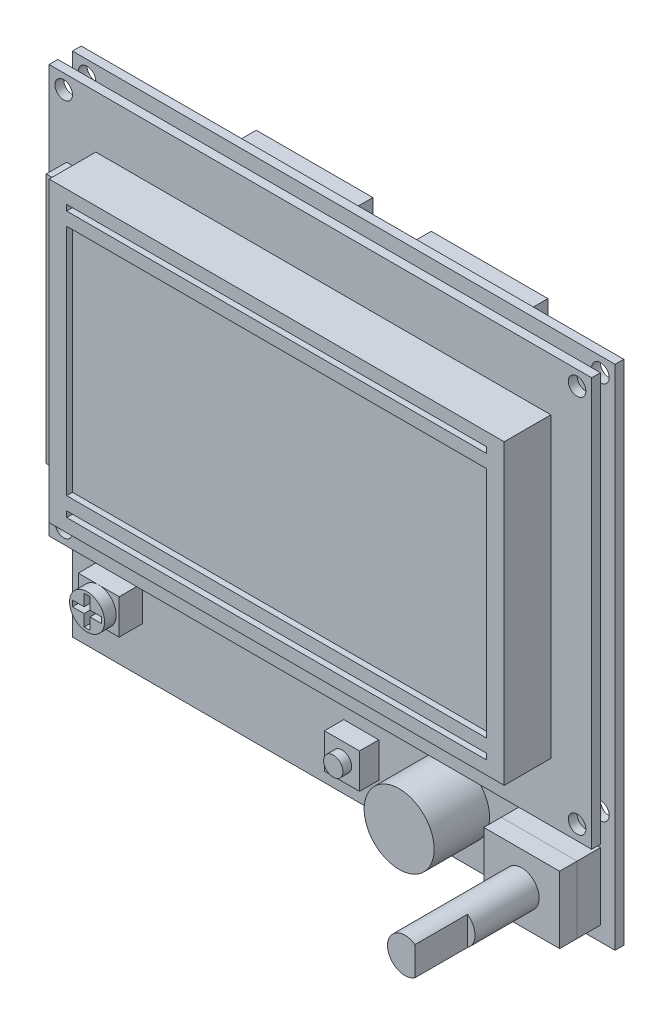
from build123d import *

# Parameters (mm, degrees)
ESQUISSE1_W             = 78
ESQUISSE1_H             = 51
BOSS_EXTRU_1_DEPTH      = 8
ESQUISSE2_W             = 72
ESQUISSE2_H             = 40
ESQUISSE2_H_2           = 1
ENL_V_MAT_EXTRU_1_DEPTH = 1
ESQUISSE3_W             = 5
ESQUISSE3_H             = 43
BOSS_EXTRU_2_DEPTH      = 3.5
ESQUISSE4_W             = 93
ESQUISSE4_H             = 70
ESQUISSE4_R             = 1.5
BOSS_EXTRU_3_DEPTH      = 1.5
ESQUISSE5_W             = 93
ESQUISSE5_H             = 87
ESQUISSE5_R             = 1.5
BOSS_EXTRU_4_DEPTH      = 1.5
BOSS_EXTRU_5_DEPTH      = 25
ESQUISSE7_W             = 20
ESQUISSE7_H             = 9
ESQUISSE7_W_2           = 18
ESQUISSE7_H_2           = 7
BOSS_EXTRU_6_DEPTH      = 9
BOSS_EXTRU_6_2_DEPTH    = 9
ESQUISSE8_W             = 13
ESQUISSE8_H             = 11.5
BOSS_EXTRU_7_DEPTH      = 4
ESQUISSE8_W_2           = 7
ESQUISSE8_H_2           = 6
BOSS_EXTRU_7_2_DEPTH    = 4
ESQUISSE9_W             = 13
ESQUISSE9_H             = 11.5
BOSS_EXTRU_8_DEPTH      = 3
ESQUISSE10_R            = 3
BOSS_EXTRU_9_DEPTH      = 20
ESQUISSE11_W            = 20.196518619
ESQUISSE11_H            = 4.923957274
ENL_V_MAT_EXTRU_2_DEPTH = 9
ESQUISSE12_R            = 6
BOSS_EXTRU_10_DEPTH     = 9.5
ESQUISSE13_R            = 3
BOSS_EXTRU_11_DEPTH     = 2
ESQUISSE14_W            = 6
ESQUISSE14_H            = 6
BOSS_EXTRU_12_DEPTH     = 3.3
ESQUISSE15_R            = 1.65
BOSS_EXTRU_13_DEPTH     = 1.5


with BuildPart() as part:
    # Esquisse1 → Boss.-Extru.1 (new body)
    with BuildSketch(Plane.XY):
        with Locations((0, 25.5)):
            Rectangle(ESQUISSE1_W, ESQUISSE1_H)
    extrude(amount=BOSS_EXTRU_1_DEPTH)

    # Esquisse2 → Enlèv. mat.-Extru.1 (cut)
    with BuildSketch(Plane.XY.offset(8)):
        with Locations((0, 25.5)):
            Rectangle(ESQUISSE2_W, ESQUISSE2_H)
        with Locations((0, 2.75)):
            Rectangle(ESQUISSE2_W, ESQUISSE2_H_2)
        with Locations((0, 48.25)):
            Rectangle(ESQUISSE2_W, ESQUISSE2_H_2)
    extrude(amount=-ENL_V_MAT_EXTRU_1_DEPTH, mode=Mode.SUBTRACT)


with BuildPart() as body_2:
    # Esquisse3 → Boss.-Extru.2 (new body)
    with BuildSketch(Plane(origin=(0, 0, 0), x_dir=(-1, 0, 0), z_dir=(0, 0, -1))):
        with Locations((41.5, 25.5)):
            Rectangle(ESQUISSE3_W, ESQUISSE3_H)
    extrude(amount=-BOSS_EXTRU_2_DEPTH)


with BuildPart() as body_3:
    # Esquisse4 → Boss.-Extru.3 (new body)
    with BuildSketch(Plane(origin=(0, 0, 0), x_dir=(-1, 0, 0), z_dir=(0, 0, -1))):
        with Locations((0.5, 25)):
            Rectangle(ESQUISSE4_W, ESQUISSE4_H)
        with Locations((-43.5, 57.5)):
            Circle(ESQUISSE4_R, mode=Mode.SUBTRACT)
        with Locations((-43.5, -7.5)):
            Circle(ESQUISSE4_R, mode=Mode.SUBTRACT)
        with Locations((44.5, 57.5)):
            Circle(ESQUISSE4_R, mode=Mode.SUBTRACT)
        with Locations((44.5, -7.5)):
            Circle(ESQUISSE4_R, mode=Mode.SUBTRACT)
    extrude(amount=BOSS_EXTRU_3_DEPTH)


with BuildPart() as body_4:
    # Esquisse5 → Boss.-Extru.4 (new body)
    with BuildSketch(Plane(origin=(0, 0, -4), x_dir=(-1, 0, 0), z_dir=(0, 0, -1))):
        with Locations((0.5, 16.5)):
            Rectangle(ESQUISSE5_W, ESQUISSE5_H)
        with Locations((-43.5, 57.5)):
            Circle(ESQUISSE5_R, mode=Mode.SUBTRACT)
        with Locations((-43.5, -7.5)):
            Circle(ESQUISSE5_R, mode=Mode.SUBTRACT)
        with Locations((44.5, -7.5)):
            Circle(ESQUISSE5_R, mode=Mode.SUBTRACT)
        with Locations((44.5, 57.5)):
            Circle(ESQUISSE5_R, mode=Mode.SUBTRACT)
    extrude(amount=BOSS_EXTRU_4_DEPTH)


with BuildPart() as body_5:
    # Esquisse6 → Boss.-Extru.5 (new body)
    with BuildSketch(Plane.ZY.offset(47)):
        Polygon((-5.5, 38.5), (-8.5, 38.5), (-8.5, 12), (-5.5, 12), (-5.5, 12.25), (-8.25, 12.25), (-8.25, 38.25), (-5.5, 38.25), align=None)
    extrude(amount=-BOSS_EXTRU_5_DEPTH)


with BuildPart() as body_6:
    # Esquisse7 → Boss.-Extru.6 (new body)
    with BuildSketch(Plane(origin=(0, 0, -5.5), x_dir=(-1, 0, 0), z_dir=(0, 0, -1))):
        with Locations((16, 49)):
            Rectangle(ESQUISSE7_W, ESQUISSE7_H)
        with Locations((16, 49)):
            Rectangle(ESQUISSE7_W_2, ESQUISSE7_H_2, mode=Mode.SUBTRACT)
    extrude(amount=BOSS_EXTRU_6_DEPTH)


with BuildPart() as body_7:
    # Esquisse7 → Boss.-Extru.6 2 (new body)
    with BuildSketch(Plane(origin=(0, 0, -5.5), x_dir=(-1, 0, 0), z_dir=(0, 0, -1))):
        with Locations((-14, 49)):
            Rectangle(ESQUISSE7_W, ESQUISSE7_H)
        with Locations((-14, 49)):
            Rectangle(ESQUISSE7_W_2, ESQUISSE7_H_2, mode=Mode.SUBTRACT)
    extrude(amount=BOSS_EXTRU_6_2_DEPTH)


with BuildPart() as body_8:
    # Esquisse8 → Boss.-Extru.7 (new body)
    with BuildSketch(Plane.XY.offset(-4)):
        with Locations((37, -18.75)):
            Rectangle(ESQUISSE8_W, ESQUISSE8_H)
    extrude(amount=BOSS_EXTRU_7_DEPTH)


with BuildPart() as body_9:
    # Esquisse8 → Boss.-Extru.7 2 (new body)
    with BuildSketch(Plane.XY.offset(-4)):
        with Locations((-38.5, -16)):
            Rectangle(ESQUISSE8_W_2, ESQUISSE8_H_2)
    extrude(amount=BOSS_EXTRU_7_2_DEPTH)


with BuildPart() as body_10:
    # Esquisse9 → Boss.-Extru.8 (new body)
    with BuildSketch(Plane.XY):
        with Locations((37, -18.75)):
            Rectangle(ESQUISSE9_W, ESQUISSE9_H)
    extrude(amount=BOSS_EXTRU_8_DEPTH)


with BuildPart() as body_11:
    # Esquisse10 → Boss.-Extru.9 (new body)
    with BuildSketch(Plane.XY.offset(3)):
        with Locations((37, -18.75)):
            Circle(ESQUISSE10_R)
    extrude(amount=BOSS_EXTRU_9_DEPTH)

    # Esquisse11 → Enlèv. mat.-Extru.2 (cut)
    with BuildSketch(Plane.XY.offset(23)):
        with Locations((48.812511681, -18.75)):
            Rectangle(ESQUISSE11_W, ESQUISSE11_H)
    extrude(amount=-ENL_V_MAT_EXTRU_2_DEPTH, mode=Mode.SUBTRACT)


with BuildPart() as body_12:
    # Esquisse12 → Boss.-Extru.10 (new body)
    with BuildSketch(Plane.XY.offset(-4)):
        with Locations((18.5, -18)):
            Circle(ESQUISSE12_R)
    extrude(amount=BOSS_EXTRU_10_DEPTH)


with BuildPart() as body_13:
    # Esquisse13 → Boss.-Extru.11 (new body)
    with BuildSketch(Plane.XY):
        with Locations((-38.5, -16)):
            Circle(ESQUISSE13_R)
        Polygon((-38, -13.5), (-39, -13.5), (-39, -15.5), (-41, -15.5), (-41, -16.5), (-39, -16.5), (-39, -18.5), (-38, -18.5), (-38, -16.5), (-36, -16.5), (-36, -15.5), (-38, -15.5), align=None, mode=Mode.SUBTRACT)
    extrude(amount=BOSS_EXTRU_11_DEPTH)


with BuildPart() as body_14:
    # Esquisse14 → Boss.-Extru.12 (new body)
    with BuildSketch(Plane.XY.offset(-4)):
        with Locations((2.5, -19)):
            Rectangle(ESQUISSE14_W, ESQUISSE14_H)
    extrude(amount=BOSS_EXTRU_12_DEPTH)


with BuildPart() as body_15:
    # Esquisse15 → Boss.-Extru.13 (new body)
    with BuildSketch(Plane.XY.offset(-0.7)):
        with Locations((2.5, -19)):
            Circle(ESQUISSE15_R)
    extrude(amount=BOSS_EXTRU_13_DEPTH)


solid = Compound([part.part, body_2.part, body_3.part, body_4.part, body_5.part, body_6.part, body_7.part, body_8.part, body_9.part, body_10.part, body_11.part, body_12.part, body_13.part, body_14.part, body_15.part])
